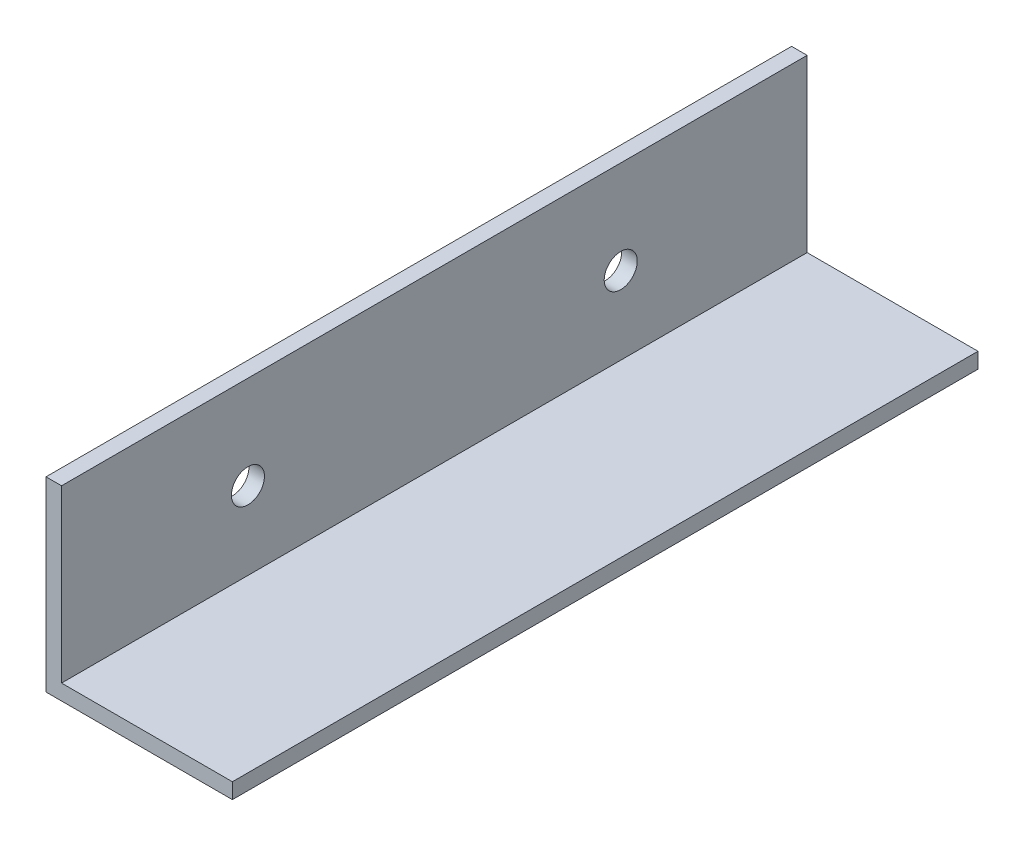
from build123d import *

# Parameters (mm, degrees)
BOSS_EXTRUDE1_DEPTH     = 152.4
F_1_4_CLEARANCE_HOLE1_D = 6.7564


with BuildPart() as part:
    # Sketch1 → Boss-Extrude1 (new body)
    with BuildSketch(Plane.XY):
        Polygon((0, 0), (0, 38.1), (3.175, 38.1), (3.175, 3.175), (38.1, 3.175), (38.1, 0), align=None)
    extrude(amount=BOSS_EXTRUDE1_DEPTH)

    # 1/4 Clearance Hole1 (through all)
    with Locations(Plane.ZY):
        with Locations((38.1, 19.05), (114.3, 19.05)):
            Hole(F_1_4_CLEARANCE_HOLE1_D / 2)


solid = part.part
